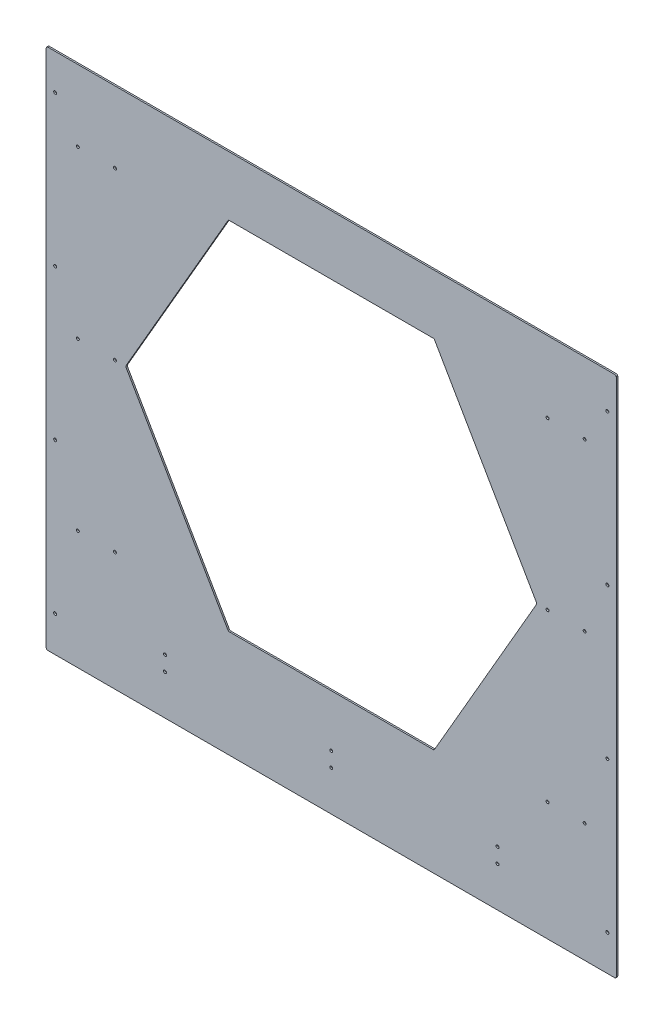
from build123d import *

# Parameters (mm, degrees)
SKETCH1_W                    = 1219.2
SKETCH1_H                    = 1016
BOSS_EXTRUDE1_DEPTH          = 3.175
F_1_4_0_25_DIAMETER_HOLE1_D  = 6.35
F_1_4_0_25_DIAMETER_HOLE2_D  = 6.35
SKETCH7_W                    = 1219.2
SKETCH7_H                    = 101.6
BOSS_EXTRUDE2_DEPTH          = 3.175
F_1_4_0_25_DIAMETER_HOLE3_D  = 6.35
FILLET1_R                    = 3.175
F_1_4_0_266_DIAMETER_HOLE1_D = 6.35


with BuildPart() as part:
    # Sketch1 → Boss-Extrude1 (new body)
    with BuildSketch(Plane.XY):
        with Locations((609.6, 508)):
            Rectangle(SKETCH1_W, SKETCH1_H)
        Polygon((1049.540905122, 508), (829.570452561, 889), (389.629547439, 889), (169.659094878, 508), (389.629547439, 127), (829.570452561, 127), align=None, mode=Mode.SUBTRACT)
    extrude(amount=BOSS_EXTRUDE1_DEPTH)

    # 1/4 (0.25) Diameter Hole1 (through all)
    with Locations(Plane.XY.offset(3.175)):
        with Locations((254, 15.875), (609.6, 15.875), (965.2, 15.875)):
            Hole(F_1_4_0_25_DIAMETER_HOLE1_D / 2)

    # 1/4 (0.25) Diameter Hole2 (through all)
    with Locations(Plane.XY.offset(3.175)):
        with Locations((1151.5725, 863.6), (67.6275, 863.6), (147.0025, 863.6), (67.6275, 152.4), (147.0025, 152.4), (67.6275, 508), (147.0025, 508), (1072.1975, 152.4), (1151.5725, 152.4), (1072.1975, 508), (1151.5725, 508), (1072.1975, 863.6)):
            Hole(F_1_4_0_25_DIAMETER_HOLE2_D / 2)

    # Sketch7 → Boss-Extrude2 (add)
    with BuildSketch(Plane.XY.offset(3.175)):
        with Locations((609.6, -50.8)):
            Rectangle(SKETCH7_W, SKETCH7_H)
    extrude(amount=-BOSS_EXTRUDE2_DEPTH)

    # 1/4 (0.25) Diameter Hole3 (through all)
    with Locations(Plane.XY.offset(3.175)):
        with Locations((965.2, -15.875), (254, -15.875), (609.6, -15.875)):
            Hole(F_1_4_0_25_DIAMETER_HOLE3_D / 2)

    # Fillet1
    fillet1_edges = [part.edges().sort_by_distance(p)[0] for p in [
        (0, -101.6, 1.5875),
        (1219.2, -101.6, 1.5875),
        (829.570452561, 127, 1.5875),
        (1049.540905122, 508, 1.5875),
        (829.570452561, 889, 1.5875),
        (389.629547439, 889, 1.5875),
        (169.659094878, 508, 1.5875),
        (389.629547439, 127, 1.5875),
        (0, 1016, 1.5875),
        (1219.2, 1016, 1.5875),
    ]]
    fillet(fillet1_edges, radius=FILLET1_R)

    # 1/4 (0.266) Diameter Hole1 (through all)
    with Locations(Plane.XY.offset(3.175)):
        with Locations((19.05, 296.333333333), (1200.15, 939.8), (1200.15, 618.066666667), (1200.15, 296.333333333), (1200.15, -25.4), (19.05, 939.8), (19.05, 618.066666667), (19.05, -25.4)):
            Hole(F_1_4_0_266_DIAMETER_HOLE1_D / 2)


solid = part.part
